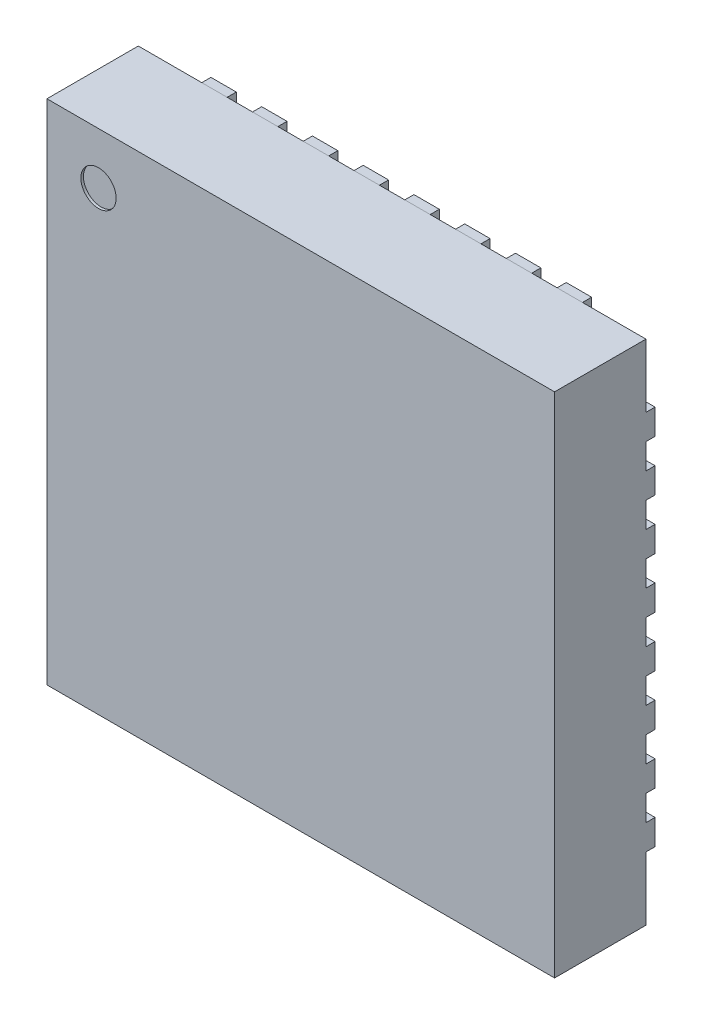
from build123d import *

# Parameters (mm, degrees)
SKETCH1_W             = 5
SKETCH1_H             = 5
BOSS_EXTRUDE1_DEPTH   = 0.9
BOSS_EXTRUDE3_DEPTH   = 0.09
BOSS_EXTRUDE3_2_DEPTH = 0.09
BOSS_EXTRUDE3_3_DEPTH = 0.09
BOSS_EXTRUDE3_4_DEPTH = 0.09
BOSS_EXTRUDE3_5_DEPTH = 0.09
BOSS_EXTRUDE3_6_DEPTH = 0.09
BOSS_EXTRUDE3_7_DEPTH = 0.09
BOSS_EXTRUDE3_8_DEPTH = 0.09
CIRPATTERN1_COUNT     = 4
SKETCH4_R             = 0.173736533
CUT_EXTRUDE1_DEPTH    = 0.0254
BOSS_EXTRUDE5_DEPTH   = 0.09


with BuildPart() as part:
    # Sketch1 → Boss-Extrude1 (new body)
    with BuildSketch(Plane.XY):
        with Locations((2.5, 2.5)):
            Rectangle(SKETCH1_W, SKETCH1_H)
    extrude(amount=BOSS_EXTRUDE1_DEPTH)


with BuildPart() as body_2:
    # Sketch2 → Boss-Extrude3 (new body)
    with BuildSketch(Plane(origin=(0, 0, 0), x_dir=(-1, 0, 0), z_dir=(0, 0, -1))):
        with BuildLine():
            Line((-0.875, 5), (-0.625, 5))
            Line((-0.625, 5), (-0.625, 4.725))
            ThreePointArc((-0.625, 4.725), (-0.75, 4.6), (-0.875, 4.725))
            Line((-0.875, 4.725), (-0.875, 5))
        make_face()
    boss_extrude3 = extrude(amount=BOSS_EXTRUDE3_DEPTH)


with BuildPart() as body_3:
    # Sketch2 → Boss-Extrude3 2 (new body)
    with BuildSketch(Plane(origin=(0, 0, 0), x_dir=(-1, 0, 0), z_dir=(0, 0, -1))):
        with BuildLine():
            Line((-1.375, 5), (-1.125, 5))
            Line((-1.125, 5), (-1.125, 4.725))
            ThreePointArc((-1.125, 4.725), (-1.25, 4.6), (-1.375, 4.725))
            Line((-1.375, 4.725), (-1.375, 5))
        make_face()
    boss_extrude3_2 = extrude(amount=BOSS_EXTRUDE3_2_DEPTH)


with BuildPart() as body_4:
    # Sketch2 → Boss-Extrude3 3 (new body)
    with BuildSketch(Plane(origin=(0, 0, 0), x_dir=(-1, 0, 0), z_dir=(0, 0, -1))):
        with BuildLine():
            Line((-1.875, 5), (-1.625, 5))
            Line((-1.625, 5), (-1.625, 4.725))
            ThreePointArc((-1.625, 4.725), (-1.75, 4.6), (-1.875, 4.725))
            Line((-1.875, 4.725), (-1.875, 5))
        make_face()
    boss_extrude3_3 = extrude(amount=BOSS_EXTRUDE3_3_DEPTH)


with BuildPart() as body_5:
    # Sketch2 → Boss-Extrude3 4 (new body)
    with BuildSketch(Plane(origin=(0, 0, 0), x_dir=(-1, 0, 0), z_dir=(0, 0, -1))):
        with BuildLine():
            Line((-2.875, 5), (-2.625, 5))
            Line((-2.625, 5), (-2.625, 4.725))
            ThreePointArc((-2.625, 4.725), (-2.75, 4.6), (-2.875, 4.725))
            Line((-2.875, 4.725), (-2.875, 5))
        make_face()
    boss_extrude3_4 = extrude(amount=BOSS_EXTRUDE3_4_DEPTH)


with BuildPart() as body_6:
    # Sketch2 → Boss-Extrude3 5 (new body)
    with BuildSketch(Plane(origin=(0, 0, 0), x_dir=(-1, 0, 0), z_dir=(0, 0, -1))):
        with BuildLine():
            Line((-2.375, 5), (-2.125, 5))
            Line((-2.125, 5), (-2.125, 4.725))
            ThreePointArc((-2.125, 4.725), (-2.25, 4.6), (-2.375, 4.725))
            Line((-2.375, 4.725), (-2.375, 5))
        make_face()
    boss_extrude3_5 = extrude(amount=BOSS_EXTRUDE3_5_DEPTH)


with BuildPart() as body_7:
    # Sketch2 → Boss-Extrude3 6 (new body)
    with BuildSketch(Plane(origin=(0, 0, 0), x_dir=(-1, 0, 0), z_dir=(0, 0, -1))):
        with BuildLine():
            Line((-3.375, 5), (-3.125, 5))
            Line((-3.125, 5), (-3.125, 4.725))
            ThreePointArc((-3.125, 4.725), (-3.25, 4.6), (-3.375, 4.725))
            Line((-3.375, 4.725), (-3.375, 5))
        make_face()
    boss_extrude3_6 = extrude(amount=BOSS_EXTRUDE3_6_DEPTH)


with BuildPart() as body_8:
    # Sketch2 → Boss-Extrude3 7 (new body)
    with BuildSketch(Plane(origin=(0, 0, 0), x_dir=(-1, 0, 0), z_dir=(0, 0, -1))):
        with BuildLine():
            Line((-3.875, 5), (-3.625, 5))
            Line((-3.625, 5), (-3.625, 4.725))
            ThreePointArc((-3.625, 4.725), (-3.75, 4.6), (-3.875, 4.725))
            Line((-3.875, 4.725), (-3.875, 5))
        make_face()
    boss_extrude3_7 = extrude(amount=BOSS_EXTRUDE3_7_DEPTH)


with BuildPart() as body_9:
    # Sketch2 → Boss-Extrude3 8 (new body)
    with BuildSketch(Plane(origin=(0, 0, 0), x_dir=(-1, 0, 0), z_dir=(0, 0, -1))):
        with BuildLine():
            Line((-4.375, 5), (-4.125, 5))
            Line((-4.125, 5), (-4.125, 4.725))
            ThreePointArc((-4.125, 4.725), (-4.25, 4.6), (-4.375, 4.725))
            Line((-4.375, 4.725), (-4.375, 5))
        make_face()
    boss_extrude3_8 = extrude(amount=BOSS_EXTRUDE3_8_DEPTH)


with BuildPart() as part_1:
    add(part.part)

    # CirPattern1: Boss-Extrude3, Boss-Extrude3 2, Boss-Extrude3 3, Boss-Extrude3 4, Boss-Extrude3 5, Boss-Extrude3 6, Boss-Extrude3 7, Boss-Extrude3 8 ×4 about axis
    cirpattern1_axis = Axis((2.5, 2.5, 0), (0, 0, 1))
    for i in range(1, CIRPATTERN1_COUNT):
        add(boss_extrude3.rotate(cirpattern1_axis, i * 360 / CIRPATTERN1_COUNT))
        add(boss_extrude3_2.rotate(cirpattern1_axis, i * 360 / CIRPATTERN1_COUNT))
        add(boss_extrude3_3.rotate(cirpattern1_axis, i * 360 / CIRPATTERN1_COUNT))
        add(boss_extrude3_4.rotate(cirpattern1_axis, i * 360 / CIRPATTERN1_COUNT))
        add(boss_extrude3_5.rotate(cirpattern1_axis, i * 360 / CIRPATTERN1_COUNT))
        add(boss_extrude3_6.rotate(cirpattern1_axis, i * 360 / CIRPATTERN1_COUNT))
        add(boss_extrude3_7.rotate(cirpattern1_axis, i * 360 / CIRPATTERN1_COUNT))
        add(boss_extrude3_8.rotate(cirpattern1_axis, i * 360 / CIRPATTERN1_COUNT))

    # Sketch4 → Cut-Extrude1 (cut)
    with BuildSketch(Plane.XY.offset(0.9)):
        with Locations((0.508, 4.492)):
            Circle(SKETCH4_R)
    extrude(amount=-CUT_EXTRUDE1_DEPTH, mode=Mode.SUBTRACT)

    # Sketch5 → Boss-Extrude5 (add)
    with BuildSketch(Plane(origin=(0, 0, 0), x_dir=(-1, 0, 0), z_dir=(0, 0, -1))):
        with BuildLine():
            Line((-4.075, 4.075), (-1.306, 4.075))
            ThreePointArc((-1.306, 4.075), (-1.194407684, 3.805592316), (-0.925, 3.694))
            Line((-0.925, 3.694), (-0.925, 0.925))
            Line((-0.925, 0.925), (-4.075, 0.925))
            Line((-4.075, 0.925), (-4.075, 4.075))
        make_face()
    extrude(amount=BOSS_EXTRUDE5_DEPTH)


solid = Compound([body_2.part, body_3.part, body_4.part, body_5.part, body_6.part, body_7.part, body_8.part, body_9.part, part_1.part])
